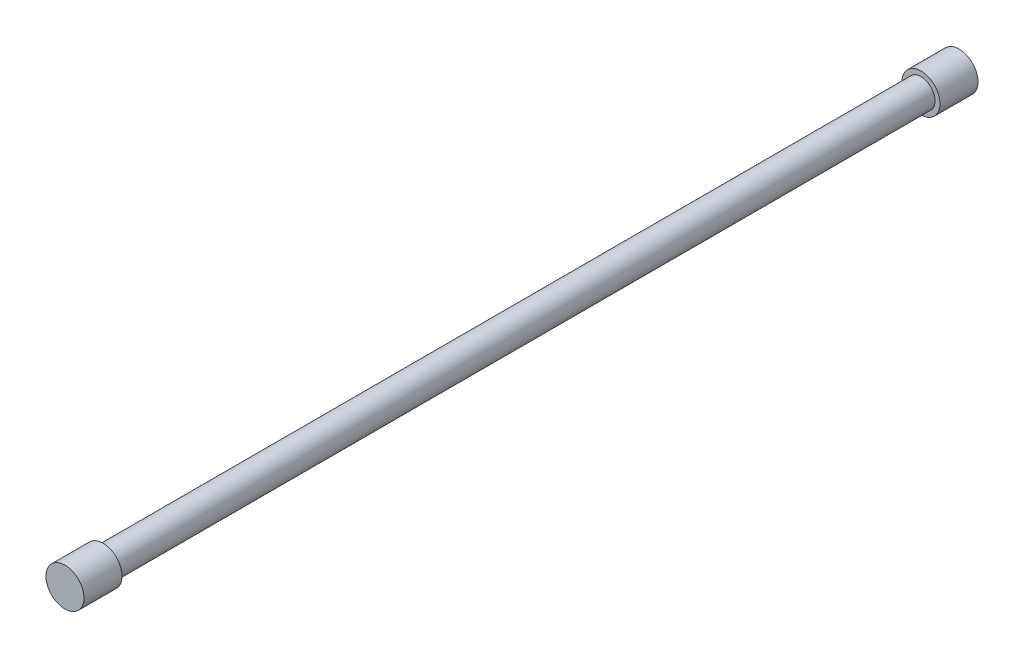
from build123d import *

# Parameters (mm, degrees)
SKETCH1_R           = 7.41
BOSS_EXTRUDE1_DEPTH = 430
SKETCH2_R           = 10
BOSS_EXTRUDE2_DEPTH = 20
SKETCH3_R           = 10
BOSS_EXTRUDE3_DEPTH = 20


with BuildPart() as part:
    # Sketch1 → Boss-Extrude1 (new body)
    with BuildSketch(Plane.XY):
        Circle(SKETCH1_R)
    extrude(amount=-BOSS_EXTRUDE1_DEPTH)

    # Sketch2 → Boss-Extrude2 (add)
    with BuildSketch(Plane(origin=(0, 0, -430), x_dir=(-1, 0, 0), z_dir=(0, 0, -1))):
        Circle(SKETCH2_R)
    extrude(amount=BOSS_EXTRUDE2_DEPTH)

    # Sketch3 → Boss-Extrude3 (add)
    with BuildSketch(Plane.XY):
        Circle(SKETCH3_R)
    extrude(amount=BOSS_EXTRUDE3_DEPTH)


solid = part.part
